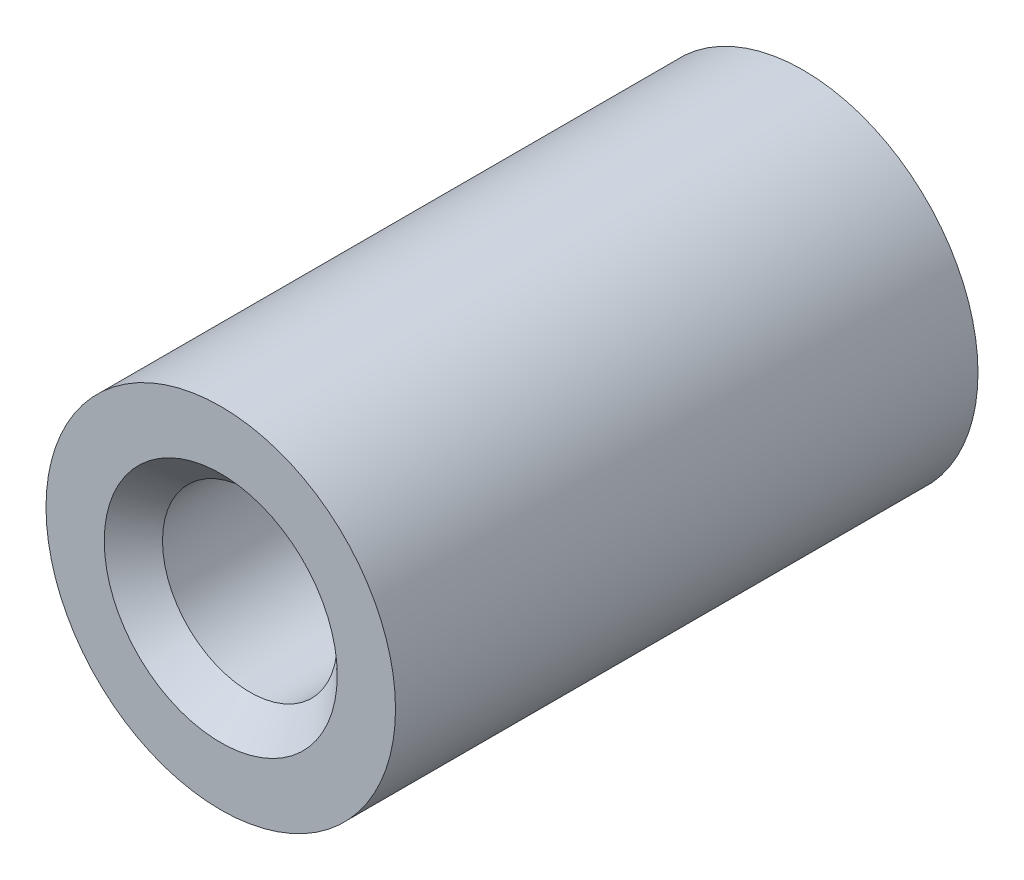
from build123d import *

# Parameters (mm, degrees)
SCHIZZO1_R                   = 3
SCHIZZO1_R_2                 = 1.5
ESTRUSIONE_ESTRUSIONE1_DEPTH = 10
SMUSSO1_SIZE                 = 0.5
CHAMFER1_SIZE                = 0.5


with BuildPart() as part:
    # Schizzo1 → Estrusione-Estrusione1 (new body)
    with BuildSketch(Plane.XY):
        Circle(SCHIZZO1_R)
        Circle(SCHIZZO1_R_2, mode=Mode.SUBTRACT)
    extrude(amount=ESTRUSIONE_ESTRUSIONE1_DEPTH)

    # Smusso1
    smusso1_edges = [part.edges().sort_by_distance(p)[0] for p in [
        (-1.5, 0, 10),
    ]]
    chamfer(smusso1_edges, length=SMUSSO1_SIZE)

    # Chamfer1
    chamfer1_edges = [part.edges().sort_by_distance(p)[0] for p in [
        (-1.5, 0, 0),
    ]]
    chamfer(chamfer1_edges, length=CHAMFER1_SIZE)


solid = part.part
